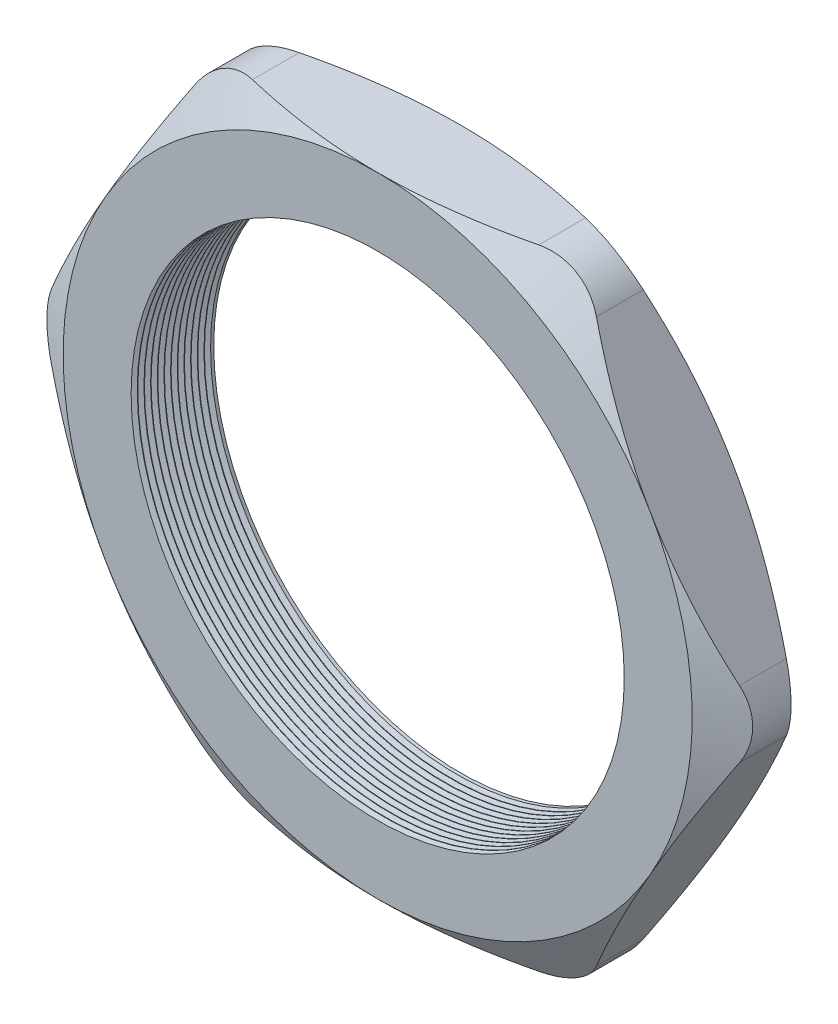
from build123d import *

# Parameters (mm, degrees)
SKETCH1_R          = 23.495
EXTRUDE1_DEPTH     = 7.874
SKETCH2_OUTSIDE_W  = 120.34
SKETCH2_OUTSIDE_H  = 111.066
SKETCH2_OUTSIDE_R  = 29.972
CUT_EXTRUDE1_DEPTH = 8.874
CUT_EXTRUDE1_DRAFT = -60
SKETCH3_OUTSIDE_W  = 120.34
SKETCH3_OUTSIDE_H  = 111.066
SKETCH3_OUTSIDE_R  = 29.972
CUT_EXTRUDE2_DEPTH = 8.874
CUT_EXTRUDE2_DRAFT = -60
FILLET1_R          = 6.35
LPATTERN1_COUNT    = 12
LPATTERN1_PITCH    = 0.635


with BuildPart() as part:
    # Sketch1 → Extrude1 (new body)
    with BuildSketch(Plane.XY):
        Polygon((-34.608684536, 0), (-17.304342268, -29.972), (17.304342268, -29.972), (34.608684536, 0), (17.304342268, 29.972), (-17.304342268, 29.972), align=None)
        Circle(SKETCH1_R, mode=Mode.SUBTRACT)
    extrude(amount=EXTRUDE1_DEPTH)


with BuildPart() as cut_extrude1_tool:
    # Sketch2 outside → Cut-Extrude1 (with draft: the straight prism first)
    with BuildSketch(Plane.XY.offset(7.874)):
        Rectangle(SKETCH2_OUTSIDE_W, SKETCH2_OUTSIDE_H)
        Circle(SKETCH2_OUTSIDE_R, mode=Mode.SUBTRACT)
    extrude(amount=-CUT_EXTRUDE1_DEPTH)
    # Cut-Extrude1: the draft: its side faces are tilted about the plane it starts from
    cut_extrude1_sides = [cut_extrude1_tool.faces().sort_by_distance(p)[0] for p in [
        (0, -55.533, 3.437),
        (60.17, 0, 3.437),
        (0, 55.533, 3.437),
        (-60.17, 0, 3.437),
        (-29.972, 0, 3.437),
    ]]
    draft(cut_extrude1_sides, Plane.XY.offset(7.874), CUT_EXTRUDE1_DRAFT)


with BuildPart() as part_1:
    add(part.part)

    # Cut-Extrude1: cut by cut_extrude1_tool
    add(cut_extrude1_tool.part, mode=Mode.SUBTRACT)


with BuildPart() as cut_extrude2_tool:
    # Sketch3 outside → Cut-Extrude2 (with draft: the straight prism first)
    with BuildSketch(Plane(origin=(0, 0, 0), x_dir=(-1, 0, 0), z_dir=(0, 0, -1))):
        Rectangle(SKETCH3_OUTSIDE_W, SKETCH3_OUTSIDE_H)
        Circle(SKETCH3_OUTSIDE_R, mode=Mode.SUBTRACT)
    extrude(amount=-CUT_EXTRUDE2_DEPTH)
    # Cut-Extrude2: the draft: its side faces are tilted about the plane it starts from
    cut_extrude2_sides = [cut_extrude2_tool.faces().sort_by_distance(p)[0] for p in [
        (0, -55.533, 4.437),
        (-60.17, 0, 4.437),
        (0, 55.533, 4.437),
        (60.17, 0, 4.437),
        (29.972, 0, 4.437),
    ]]
    draft(cut_extrude2_sides, Plane(origin=(0, 0, 0), x_dir=(-1, 0, 0), z_dir=(0, 0, -1)), CUT_EXTRUDE2_DRAFT)


with BuildPart() as part_2:
    add(part_1.part)

    # Cut-Extrude2: cut by cut_extrude2_tool
    add(cut_extrude2_tool.part, mode=Mode.SUBTRACT)

    # Fillet1
    fillet1_edges = [part_2.edges().sort_by_distance(p)[0] for p in [
        (34.608684536, 0, 3.937),
        (17.304342268, -29.972, 3.937),
        (-17.304342268, -29.972, 3.937),
        (-34.608684536, 0, 3.937),
        (-17.304342268, 29.972, 3.937),
        (17.304342268, 29.972, 3.937),
    ]]
    fillet(fillet1_edges, radius=FILLET1_R)

    # Sketch4 → Cut-Revolve1 (revolve, cut)
    with BuildSketch(Plane(origin=(0, 0, 0), x_dir=(1, 0, 0), z_dir=(0, 1, 0)), mode=Mode.PRIVATE) as cut_revolve1_sk:
        Polygon((-23.495, -7.874), (-23.495, -7.287412127), (-24.003, -7.580706063), align=None)
    cut_revolve1 = revolve(cut_revolve1_sk.sketch.rotate(Axis((0, 0, 0), (0, 0, 1)), 180), axis=Axis((0, 0, 0), (0, 0, 1)), mode=Mode.SUBTRACT)  # turned: the seam where the file's is

    # LPattern1: Cut-Revolve1 ×12
    with Locations(*[(0, 0, -i * LPATTERN1_PITCH) for i in range(1, LPATTERN1_COUNT)]):
        add(cut_revolve1, mode=Mode.SUBTRACT)


solid = part_2.part
